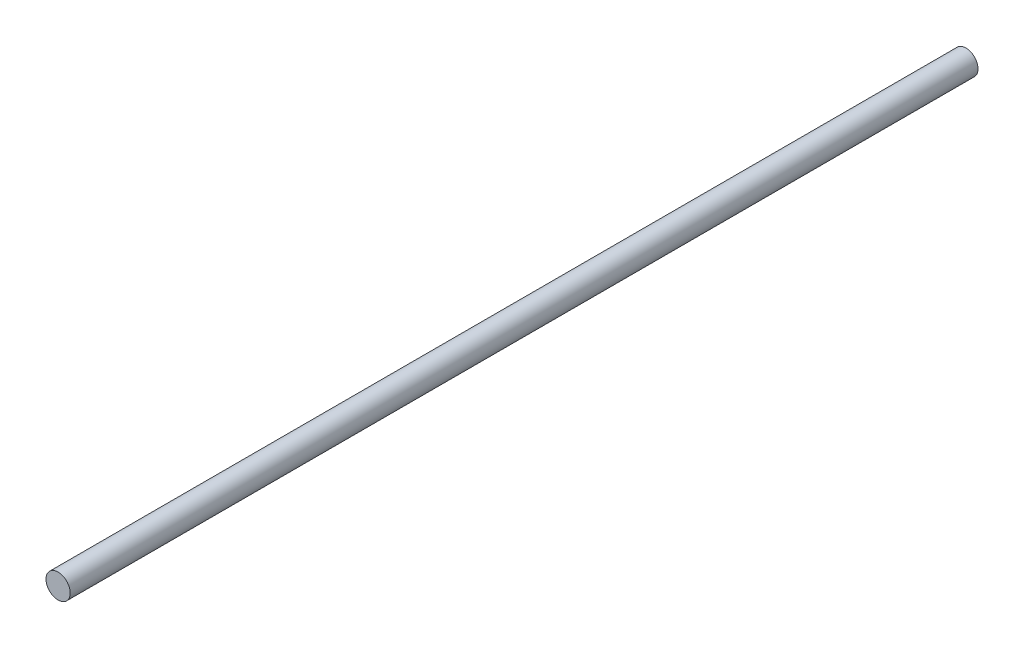
from build123d import *

# Parameters (mm, degrees)
CROQUIS1_R              = 1
SALIENTE_EXTRUIR1_DEPTH = 75


with BuildPart() as part:
    # Croquis1 → Saliente-Extruir1 (new body)
    with BuildSketch(Plane.XY):
        Circle(CROQUIS1_R)
    extrude(amount=SALIENTE_EXTRUIR1_DEPTH)


solid = part.part
